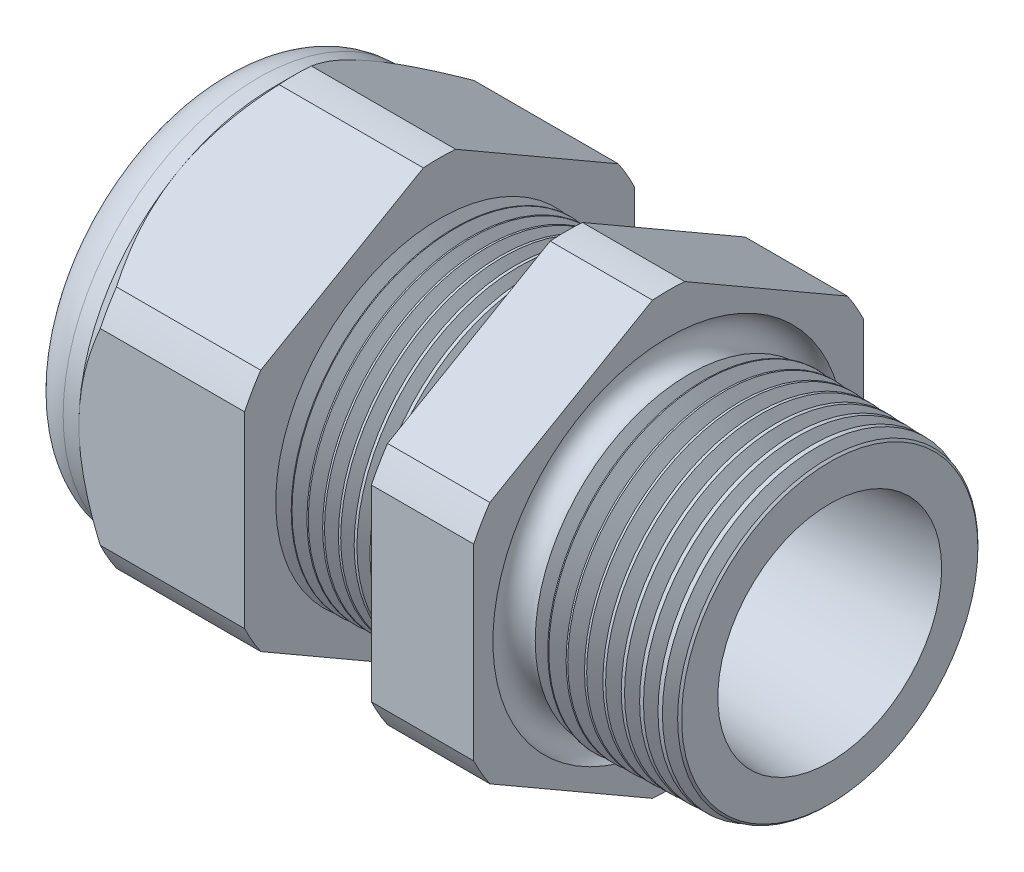
from build123d import *

# Parameters (mm, degrees)
SKETCH12_OUTSIDE_W = 52.432
SKETCH12_OUTSIDE_H = 52.432
CUT_EXTRUDE2_DEPTH = 28.172
FILLET4_R          = 2.032
SKETCH19_OUTSIDE_W = 33.316
SKETCH19_OUTSIDE_H = 35.412
SKETCH19_OUTSIDE_R = 9.525
CUT_EXTRUDE3_DEPTH = 1.999996
CUT_EXTRUDE3_DRAFT = -45
CHAMFER1_SIZE      = 0.260919487
CHAMFER1_SIZE2     = 0.254
SKETCH21_R         = 3.937
PLUG_DEPTH         = 3.81
SKETCH22_R         = 3.683
CUT_EXTRUDE4_DEPTH = 0.508
SKETCH27_R         = 0.762
PLUGHOLES_DEPTH    = 30.464
CIRPATTERN1_COUNT  = 3
SKETCH28_R         = 0.762
MIDHOLE_DEPTH      = 30.464
LPATTERN1_COUNT    = 8
LPATTERN1_PITCH    = 0.762
LPATTERN2_COUNT    = 9
LPATTERN2_PITCH    = 0.889
SKETCH32_R         = 0.889


with BuildPart() as part:
    # Sketch10 → Revolve2 (revolve)
    with BuildSketch(Plane.XY, mode=Mode.PRIVATE) as revolve2_sk:
        Polygon((-29.972, 3.937), (-19.072, 3.937), (0, 5.469582104), (0, 7.501582104), (-7.874, 7.70777005), (-7.874, 19.05), (-12.874, 19.05), (-12.874, 7.838699658), (-19.072, 8.001), (-19.072, 19.05), (-27.172, 19.05), (-27.172, 9.525), (-29.972, 9.525), align=None)
    revolve(revolve2_sk.sketch.rotate(Axis((0, 0, 0), (-1, 0, 0)), 90), axis=Axis((0, 0, 0), (-1, 0, 0)))  # turned: the seam where the file's is

    # Sketch12 outside → Cut-Extrude2 (cut, through all)
    with BuildSketch(Plane.ZY.offset(27.172)):
        Rectangle(SKETCH12_OUTSIDE_W, SKETCH12_OUTSIDE_H)
        with BuildLine():
            Line((-0.788451287, 10.543310065), (-8.736548713, 5.954473877))
            ThreePointArc((-8.736548713, 5.954473877), (-9.156270088, 5.286375), (-9.525, 4.588836188))
            Line((-9.525, 4.588836188), (-9.525, -4.588836188))
            ThreePointArc((-9.525, -4.588836188), (-9.156270088, -5.286375), (-8.736548713, -5.954473877))
            Line((-8.736548713, -5.954473877), (-0.788451287, -10.543310065))
            ThreePointArc((-0.788451287, -10.543310065), (0, -10.57275), (0.788451287, -10.543310065))
            Line((0.788451287, -10.543310065), (8.736548713, -5.954473877))
            ThreePointArc((8.736548713, -5.954473877), (9.156270088, -5.286375), (9.525, -4.588836188))
            Line((9.525, -4.588836188), (9.525, 4.588836188))
            ThreePointArc((9.525, 4.588836188), (9.156270088, 5.286375), (8.736548713, 5.954473877))
            Line((8.736548713, 5.954473877), (0.788451287, 10.543310065))
            ThreePointArc((0.788451287, 10.543310065), (0, 10.57275), (-0.788451287, 10.543310065))
        make_face(mode=Mode.SUBTRACT)
    extrude(amount=-CUT_EXTRUDE2_DEPTH, mode=Mode.SUBTRACT)

    # Fillet4
    fillet4_edges = [part.edges().sort_by_distance(p)[0] for p in [
        (-29.972, 0, 9.525),
    ]]
    fillet(fillet4_edges, radius=FILLET4_R)


with BuildPart() as cut_extrude3_tool:
    # Sketch19 outside → Cut-Extrude3 (with draft: the straight prism first)
    with BuildSketch(Plane.ZY.offset(27.172)):
        Rectangle(SKETCH19_OUTSIDE_W, SKETCH19_OUTSIDE_H)
        Circle(SKETCH19_OUTSIDE_R, mode=Mode.SUBTRACT)
    extrude(amount=-CUT_EXTRUDE3_DEPTH)
    # Cut-Extrude3: the draft: its side faces are tilted about the plane it starts from
    cut_extrude3_sides = [cut_extrude3_tool.faces().sort_by_distance(p)[0] for p in [
        (-26.172002, -17.706, 0),
        (-26.172002, 0, 16.658),
        (-26.172002, 17.706, 0),
        (-26.172002, 0, -16.658),
        (-26.172002, 0, -9.525),
    ]]
    draft(cut_extrude3_sides, Plane.ZY.offset(27.172), CUT_EXTRUDE3_DRAFT)


with BuildPart() as part_1:
    add(part.part)

    # Cut-Extrude3: cut by cut_extrude3_tool
    add(cut_extrude3_tool.part, mode=Mode.SUBTRACT)

    # Chamfer1
    chamfer1_edges = [part_1.edges().sort_by_distance(p)[0] for p in [
        (0, 0, 7.501582104),
    ]]
    chamfer1_side = [part_1.faces().sort_by_distance(p)[0] for p in [
        (0, 0, 5.681758887),
    ]]
    chamfer(chamfer1_edges, length=CHAMFER1_SIZE, length2=CHAMFER1_SIZE2, reference=chamfer1_side[0])

    # Sketch29 → Cut-Revolve1 (revolve, cut)
    with BuildSketch(Plane.XY, mode=Mode.PRIVATE) as cut_revolve1_sk:
        Polygon((-19.072, 8.001), (-18.339016419, 7.981806149), (-18.722130572, 7.356620673), align=None)
    cut_revolve1 = revolve(cut_revolve1_sk.sketch.rotate(Axis((0, 0, 0), (-1, 0, 0)), 90), axis=Axis((0, 0, 0), (-1, 0, 0)), mode=Mode.SUBTRACT)  # turned: the seam where the file's is

    # LPattern1: Cut-Revolve1 ×8
    with Locations(*[(i * LPATTERN1_PITCH, 0, 0) for i in range(1, LPATTERN1_COUNT)]):
        add(cut_revolve1, mode=Mode.SUBTRACT)

    # Sketch30 → Cut-Revolve2 (revolve, cut)
    with BuildSketch(Plane.XY, mode=Mode.PRIVATE) as cut_revolve2_sk:
        Polygon((-7.874, 7.70777005), (-6.994419703, 7.68473743), (-7.454156686, 6.934514858), align=None)
    cut_revolve2 = revolve(cut_revolve2_sk.sketch.rotate(Axis((0, 0, 0), (-1, 0, 0)), 270), axis=Axis((0, 0, 0), (-1, 0, 0)), mode=Mode.SUBTRACT)  # turned: the seam where the file's is

    # LPattern2: Cut-Revolve2 ×9
    with Locations(*[(i * LPATTERN2_PITCH, 0, 0) for i in range(1, LPATTERN2_COUNT)]):
        add(cut_revolve2, mode=Mode.SUBTRACT)

    # Sketch32 → Cut-Revolve3 (revolve, cut)
    with BuildSketch(Plane.XY, mode=Mode.PRIVATE) as cut_revolve3_sk:
        with Locations((-7.747, 7.70777005)):
            Circle(SKETCH32_R)
    revolve(cut_revolve3_sk.sketch.rotate(Axis((0, 0, 0), (-1, 0, 0)), 270), axis=Axis((0, 0, 0), (-1, 0, 0)), mode=Mode.SUBTRACT)  # turned: the seam where the file's is


with BuildPart() as body_2:
    # Sketch21 → plug (new body)
    with BuildSketch(Plane.ZY.offset(29.972)):
        Circle(SKETCH21_R)
    extrude(amount=-PLUG_DEPTH)

    # Sketch22 → Cut-Extrude4 (cut)
    with BuildSketch(Plane.ZY.offset(29.972)):
        Circle(SKETCH22_R)
    extrude(amount=-CUT_EXTRUDE4_DEPTH, mode=Mode.SUBTRACT)

    # Sketch27 → plugholes (cut, through all)
    with BuildSketch(Plane.ZY.offset(29.464)):
        with Locations((-2.917952, 0)):
            Circle(SKETCH27_R)
    plugholes = extrude(amount=-PLUGHOLES_DEPTH, mode=Mode.SUBTRACT)

    # CirPattern1: plugholes ×3 about axis
    cirpattern1_axis = Axis((0, 0, 0), (1, 0, 0))
    for i in range(1, CIRPATTERN1_COUNT):
        add(plugholes.rotate(cirpattern1_axis, i * 360 / CIRPATTERN1_COUNT), mode=Mode.SUBTRACT)

    # Sketch28 → midhole (cut, through all)
    with BuildSketch(Plane.ZY.offset(29.464)):
        Circle(SKETCH28_R)
    extrude(amount=-MIDHOLE_DEPTH, mode=Mode.SUBTRACT)


solid = Compound([part_1.part, body_2.part])
